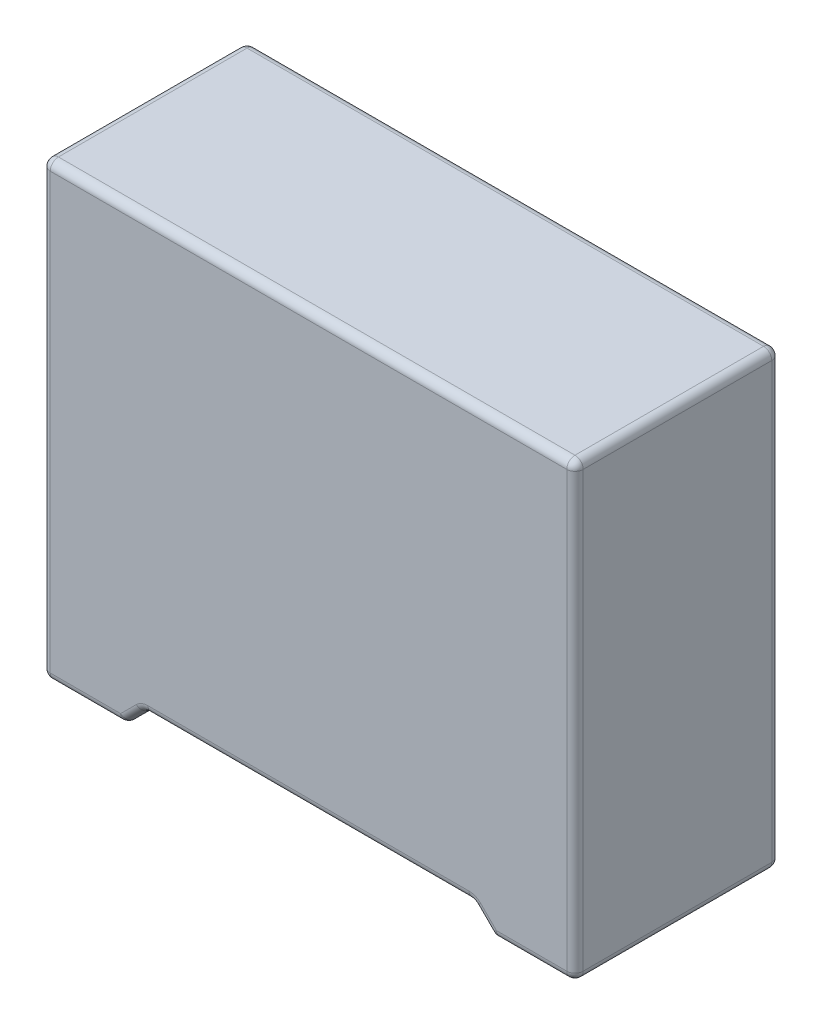
from build123d import *

# Parameters (mm, degrees)
SKETCH1_W           = 13
SKETCH1_H           = 5
BOSS_EXTRUDE1_DEPTH = 11
CUT_EXTRUDE1_DEPTH  = 6
SKETCH3_R           = 0.3
BOSS_EXTRUDE2_DEPTH = 1
FILLET1_R           = 0.2


with BuildPart() as part:
    # Sketch1 → Boss-Extrude1 (new body)
    with BuildSketch(Plane(origin=(0, 0, 0), x_dir=(1, 0, 0), z_dir=(0, 1, 0))):
        Rectangle(SKETCH1_W, SKETCH1_H)
    extrude(amount=BOSS_EXTRUDE1_DEPTH)

    # Sketch2 → Cut-Extrude1 (cut, through all)
    with BuildSketch(Plane.XY.offset(2.5)):
        Polygon((-4.5, 0), (-4, 0.5), (4, 0.5), (4.5, 0), (4.5, -1.5), (-4.5, -1.5), align=None)
    extrude(amount=-CUT_EXTRUDE1_DEPTH, mode=Mode.SUBTRACT)

    # Sketch3 → Boss-Extrude2 (add)
    with BuildSketch(Plane.XZ):
        with Locations((5, 0)):
            Circle(SKETCH3_R)
        with Locations((-5, 0)):
            Circle(SKETCH3_R)
    extrude(amount=BOSS_EXTRUDE2_DEPTH)

    # Fillet1
    fillet1_edges = [part.edges().sort_by_distance(p)[0] for p in [
        (6.5, 11, 0),
        (0, 11, -2.5),
        (-5.5, 0, -2.5),
        (5.5, 0, 2.5),
        (4.25, 0.25, 2.5),
        (0, 0.5, 2.5),
        (-4.25, 0.25, 2.5),
        (-4.25, 0.25, -2.5),
        (-4.5, 0, 0),
        (0, 0.5, -2.5),
        (-4, 0.5, 0),
        (4.25, 0.25, -2.5),
        (4, 0.5, 0),
        (4.5, 0, 0),
        (-6.5, 11, 0),
        (5.5, 0, -2.5),
        (6.5, 0, 0),
        (-5.5, 0, 2.5),
        (-6.5, 0, 0),
        (0, 11, 2.5),
        (-6.5, 5.5, -2.5),
        (6.5, 5.5, -2.5),
        (6.5, 5.5, 2.5),
        (-6.5, 5.5, 2.5),
    ]]
    fillet(fillet1_edges, radius=FILLET1_R)


solid = part.part
